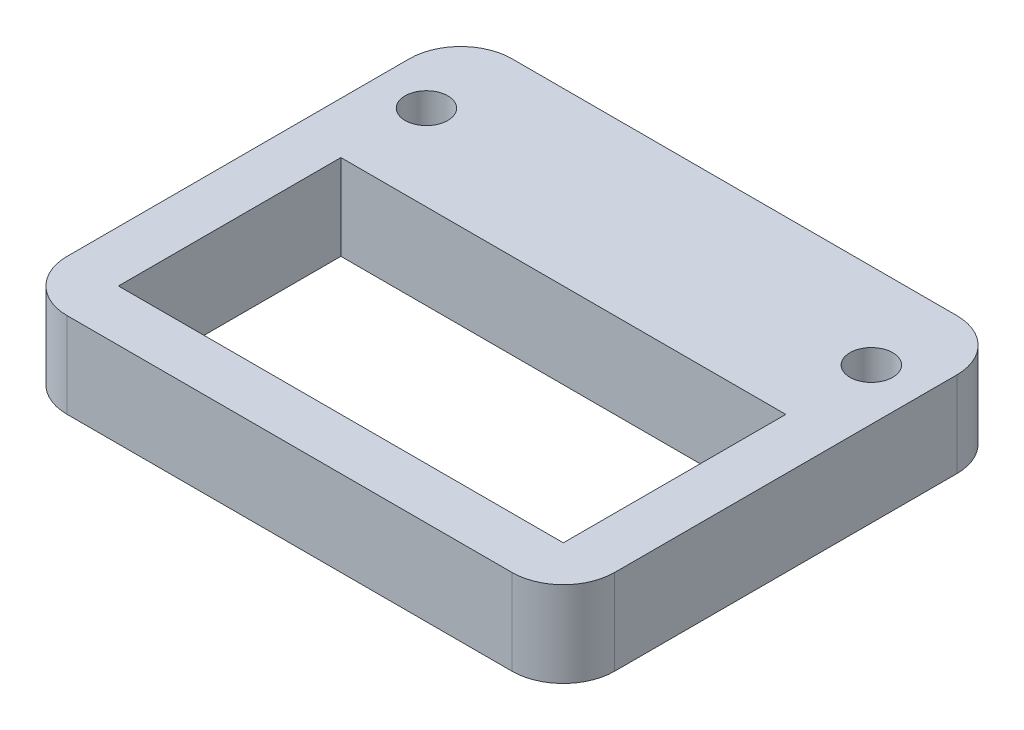
from build123d import *

# Parameters (mm, degrees)
SKETCH1_W           = 32
SKETCH1_H           = 26
SKETCH1_R           = 1.25
SKETCH1_W_2         = 26
SKETCH1_H_2         = 13
BOSS_EXTRUDE1_DEPTH = 5
FILLET1_R           = 3


with BuildPart() as part:
    # Sketch1 → Boss-Extrude1 (new body)
    with BuildSketch(Plane(origin=(0, 0, 0), x_dir=(1, 0, 0), z_dir=(0, 1, 0))):
        with Locations((16, 13)):
            Rectangle(SKETCH1_W, SKETCH1_H)
        with Locations((3, 21)):
            Circle(SKETCH1_R, mode=Mode.SUBTRACT)
        with Locations((29, 21)):
            Circle(SKETCH1_R, mode=Mode.SUBTRACT)
        with Locations((16, 9.5)):
            Rectangle(SKETCH1_W_2, SKETCH1_H_2, mode=Mode.SUBTRACT)
    extrude(amount=BOSS_EXTRUDE1_DEPTH)

    # Fillet1
    fillet1_edges = [part.edges().sort_by_distance(p)[0] for p in [
        (0, 2.5, -26),
        (32, 2.5, -26),
        (32, 2.5, 0),
        (0, 2.5, 0),
    ]]
    fillet(fillet1_edges, radius=FILLET1_R)


solid = part.part
